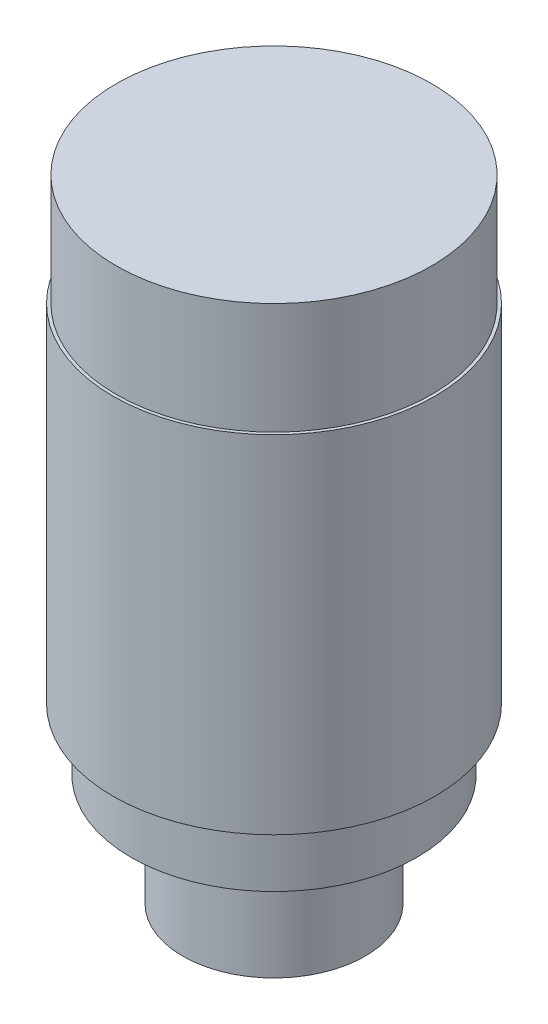
from build123d import *

# Parameters (mm, degrees)
SKETCH1_R           = 14.75
BOSS_EXTRUDE1_DEPTH = 18
SKETCH2_R           = 23.1
BOSS_EXTRUDE2_DEPTH = 10
SKETCH3_R           = 26
BOSS_EXTRUDE3_DEPTH = 74
SKETCH4_R           = 26
SKETCH4_R_2         = 25.5
CUT_EXTRUDE1_DEPTH  = 18


with BuildPart() as part:
    # Sketch1 → Boss-Extrude1 (new body)
    with BuildSketch(Plane(origin=(0, 0, 0), x_dir=(1, 0, 0), z_dir=(0, 1, 0))):
        Circle(SKETCH1_R)
    extrude(amount=BOSS_EXTRUDE1_DEPTH)

    # Sketch2 → Boss-Extrude2 (add)
    with BuildSketch(Plane(origin=(0, 18, 0), x_dir=(1, 0, 0), z_dir=(0, 1, 0))):
        Circle(SKETCH2_R)
    extrude(amount=BOSS_EXTRUDE2_DEPTH)

    # Sketch3 → Boss-Extrude3 (add)
    with BuildSketch(Plane(origin=(0, 28, 0), x_dir=(1, 0, 0), z_dir=(0, 1, 0))):
        Circle(SKETCH3_R)
    extrude(amount=BOSS_EXTRUDE3_DEPTH)

    # Sketch4 → Cut-Extrude1 (cut)
    with BuildSketch(Plane(origin=(0, 102, 0), x_dir=(1, 0, 0), z_dir=(0, 1, 0))):
        Circle(SKETCH4_R)
        Circle(SKETCH4_R_2, mode=Mode.SUBTRACT)
    extrude(amount=-CUT_EXTRUDE1_DEPTH, mode=Mode.SUBTRACT)


solid = part.part
